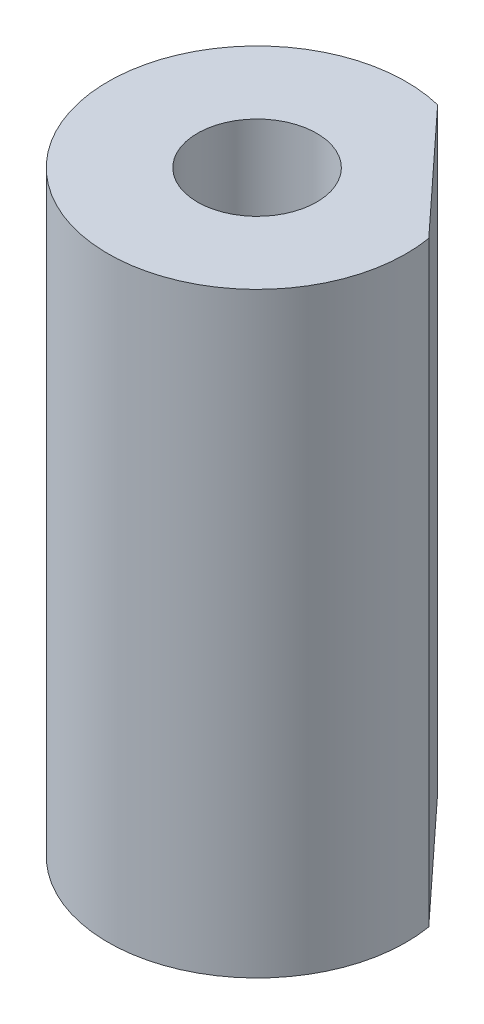
from build123d import *

# Parameters (mm, degrees)
SKETCH1_R           = 12.5
SKETCH1_R_2         = 5
BOSS_EXTRUDE1_DEPTH = 50
CUT_EXTRUDE1_DEPTH  = 51


with BuildPart() as part:
    # Sketch1 → Boss-Extrude1 (new body)
    with BuildSketch(Plane(origin=(0, 0, 0), x_dir=(1, 0, 0), z_dir=(0, 1, 0))):
        Circle(SKETCH1_R)
        Circle(SKETCH1_R_2, mode=Mode.SUBTRACT)
    extrude(amount=BOSS_EXTRUDE1_DEPTH)

    # Sketch2 → Cut-Extrude1 (cut, through all)
    with BuildSketch(Plane(origin=(0, 50, 0), x_dir=(1, 0, 0), z_dir=(0, 1, 0))):
        with BuildLine():
            Line((3.00354867, 12.133783226), (12.327918565, 2.06698424))
            ThreePointArc((12.327918565, 2.06698424), (9.170527922, 8.494199058), (3.00354867, 12.133783226))
        make_face()
    extrude(amount=-CUT_EXTRUDE1_DEPTH, mode=Mode.SUBTRACT)


solid = part.part
